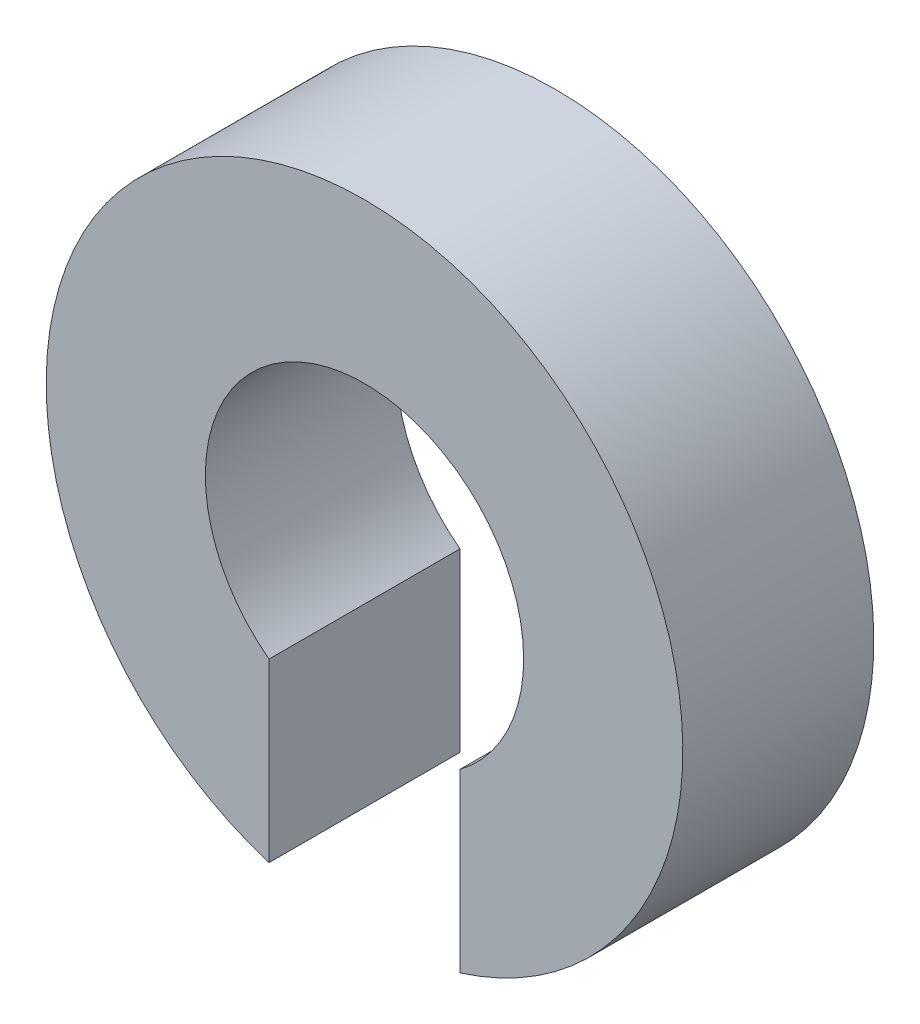
from build123d import *

# Parameters (mm, degrees)
EXTRUDE_1_DEPTH = 3


with BuildPart() as part:
    # ｽｹｯﾁ1 → ﾎﾞｽ - 押し出し1 (new body)
    with BuildSketch(Plane.XY):
        with BuildLine():
            Line((-1.5, -4.769696007), (-1.5, -2))
            ThreePointArc((-1.5, -2), (0, 2.5), (1.5, -2))
            Line((1.5, -2), (1.5, -4.769696007))
            ThreePointArc((1.5, -4.769696007), (0, 5), (-1.5, -4.769696007))
        make_face()
    extrude(amount=EXTRUDE_1_DEPTH)


solid = part.part
